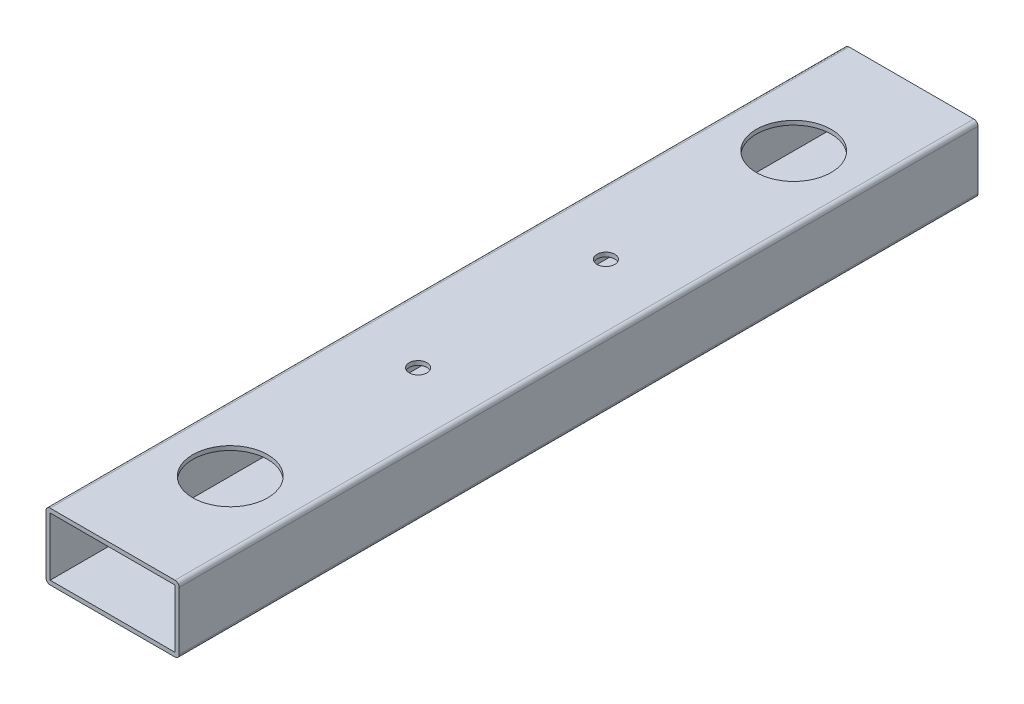
from build123d import *

# Parameters (mm, degrees)
SKETCH1_W                      = 47.625
SKETCH1_H                      = 22.225
BOSS_EXTRUDE1_DEPTH            = 304.8
CUT_EXTRUDE1_REACH             = 27.4
SKETCH2_R                      = 14.2875
CUT_EXTRUDE1_DIRECTION_2_DEPTH = 1
CUT_EXTRUDE2_REACH             = 27.4
SKETCH3_R                      = 12.7
CUT_EXTRUDE2_DIRECTION_2_DEPTH = 1
CUT_EXTRUDE3_REACH             = 27.4
SKETCH4_R                      = 3.3782
CUT_EXTRUDE3_DIRECTION_2_DEPTH = 1
CUT_EXTRUDE4_REACH             = 27.4
SKETCH5_R                      = 7.9375
CUT_EXTRUDE4_DIRECTION_2_DEPTH = 1


with BuildPart() as part:
    # Sketch1 → Boss-Extrude1 (new body)
    with BuildSketch(Plane.XY):
        with BuildLine():
            Line((-23.8125, -12.7), (23.8125, -12.7))
            ThreePointArc((23.8125, -12.7), (24.935032015, -12.235032015), (25.4, -11.1125))
            Line((25.4, -11.1125), (25.4, 11.1125))
            ThreePointArc((25.4, 11.1125), (24.935032015, 12.235032015), (23.8125, 12.7))
            Line((23.8125, 12.7), (-23.8125, 12.7))
            ThreePointArc((-23.8125, 12.7), (-24.935032015, 12.235032015), (-25.4, 11.1125))
            Line((-25.4, 11.1125), (-25.4, -11.1125))
            ThreePointArc((-25.4, -11.1125), (-24.935032015, -12.235032015), (-23.8125, -12.7))
        make_face()
        Rectangle(SKETCH1_W, SKETCH1_H, mode=Mode.SUBTRACT)
    extrude(amount=BOSS_EXTRUDE1_DEPTH)

    # Sketch2 → Cut-Extrude1 (cut, up to next)
    with BuildSketch(Plane(origin=(0, 12.7, 0), x_dir=(1, 0, 0), z_dir=(0, 1, 0)), mode=Mode.PRIVATE) as cut_extrude1_sk1:
        with Locations((0, -259.900000011)):
            Circle(SKETCH2_R)
    cut_extrude1_tool1 = extrude(cut_extrude1_sk1.sketch, amount=-CUT_EXTRUDE1_REACH, mode=Mode.PRIVATE) & part.part
    add(cut_extrude1_tool1.solids().sort_by_distance((0, 12.7, 259.9))[0], mode=Mode.SUBTRACT)
    # Sketch2 → Cut-Extrude1 (cut, up to next)
    with BuildSketch(Plane(origin=(0, 12.7, 0), x_dir=(1, 0, 0), z_dir=(0, 1, 0)), mode=Mode.PRIVATE) as cut_extrude1_sk2:
        with Locations((0, -44.899999989)):
            Circle(SKETCH2_R)
    cut_extrude1_tool2 = extrude(cut_extrude1_sk2.sketch, amount=-CUT_EXTRUDE1_REACH, mode=Mode.PRIVATE) & part.part
    add(cut_extrude1_tool2.solids().sort_by_distance((0, 12.7, 44.9))[0], mode=Mode.SUBTRACT)

    # Sketch2 → Cut-Extrude1 direction 2 (cut)
    with BuildSketch(Plane(origin=(0, 12.7, 0), x_dir=(1, 0, 0), z_dir=(0, 1, 0))):
        with Locations((0, -259.900000011)):
            Circle(SKETCH2_R)
        with Locations((0, -44.899999989)):
            Circle(SKETCH2_R)
    extrude(amount=CUT_EXTRUDE1_DIRECTION_2_DEPTH, mode=Mode.SUBTRACT)

    # Sketch3 → Cut-Extrude2 (cut, up to next)
    with BuildSketch(Plane.XZ.offset(12.7), mode=Mode.PRIVATE) as cut_extrude2_sk1:
        with Locations((0, 44.899999989)):
            Circle(SKETCH3_R)
    cut_extrude2_tool1 = extrude(cut_extrude2_sk1.sketch, amount=-CUT_EXTRUDE2_REACH, mode=Mode.PRIVATE) & part.part
    add(cut_extrude2_tool1.solids().sort_by_distance((0, -12.7, 44.9))[0], mode=Mode.SUBTRACT)
    # Sketch3 → Cut-Extrude2 (cut, up to next)
    with BuildSketch(Plane.XZ.offset(12.7), mode=Mode.PRIVATE) as cut_extrude2_sk2:
        with Locations((0, 259.900000011)):
            Circle(SKETCH3_R)
    cut_extrude2_tool2 = extrude(cut_extrude2_sk2.sketch, amount=-CUT_EXTRUDE2_REACH, mode=Mode.PRIVATE) & part.part
    add(cut_extrude2_tool2.solids().sort_by_distance((0, -12.7, 259.9))[0], mode=Mode.SUBTRACT)

    # Sketch3 → Cut-Extrude2 direction 2 (cut)
    with BuildSketch(Plane.XZ.offset(12.7)):
        with Locations((0, 44.899999989)):
            Circle(SKETCH3_R)
        with Locations((0, 259.900000011)):
            Circle(SKETCH3_R)
    extrude(amount=CUT_EXTRUDE2_DIRECTION_2_DEPTH, mode=Mode.SUBTRACT)

    # Sketch4 → Cut-Extrude3 (cut, up to next)
    with BuildSketch(Plane(origin=(0, 12.7, 0), x_dir=(1, 0, 0), z_dir=(0, 1, 0)), mode=Mode.PRIVATE) as cut_extrude3_sk1:
        with Locations((0, -188.233332829)):
            Circle(SKETCH4_R)
    cut_extrude3_tool1 = extrude(cut_extrude3_sk1.sketch, amount=-CUT_EXTRUDE3_REACH, mode=Mode.PRIVATE) & part.part
    add(cut_extrude3_tool1.solids().sort_by_distance((0, 12.7, 188.233333))[0], mode=Mode.SUBTRACT)
    # Sketch4 → Cut-Extrude3 (cut, up to next)
    with BuildSketch(Plane(origin=(0, 12.7, 0), x_dir=(1, 0, 0), z_dir=(0, 1, 0)), mode=Mode.PRIVATE) as cut_extrude3_sk2:
        with Locations((0, -116.566667171)):
            Circle(SKETCH4_R)
    cut_extrude3_tool2 = extrude(cut_extrude3_sk2.sketch, amount=-CUT_EXTRUDE3_REACH, mode=Mode.PRIVATE) & part.part
    add(cut_extrude3_tool2.solids().sort_by_distance((0, 12.7, 116.566667))[0], mode=Mode.SUBTRACT)

    # Sketch4 → Cut-Extrude3 direction 2 (cut)
    with BuildSketch(Plane(origin=(0, 12.7, 0), x_dir=(1, 0, 0), z_dir=(0, 1, 0))):
        with Locations((0, -188.233332829)):
            Circle(SKETCH4_R)
        with Locations((0, -116.566667171)):
            Circle(SKETCH4_R)
    extrude(amount=CUT_EXTRUDE3_DIRECTION_2_DEPTH, mode=Mode.SUBTRACT)

    # Sketch5 → Cut-Extrude4 (cut, up to next)
    with BuildSketch(Plane.XZ.offset(12.7), mode=Mode.PRIVATE) as cut_extrude4_sk1:
        with Locations((0, 116.566667171)):
            Circle(SKETCH5_R)
    cut_extrude4_tool1 = extrude(cut_extrude4_sk1.sketch, amount=-CUT_EXTRUDE4_REACH, mode=Mode.PRIVATE) & part.part
    add(cut_extrude4_tool1.solids().sort_by_distance((0, -12.7, 116.566667))[0], mode=Mode.SUBTRACT)
    # Sketch5 → Cut-Extrude4 (cut, up to next)
    with BuildSketch(Plane.XZ.offset(12.7), mode=Mode.PRIVATE) as cut_extrude4_sk2:
        with Locations((0, 188.233332829)):
            Circle(SKETCH5_R)
    cut_extrude4_tool2 = extrude(cut_extrude4_sk2.sketch, amount=-CUT_EXTRUDE4_REACH, mode=Mode.PRIVATE) & part.part
    add(cut_extrude4_tool2.solids().sort_by_distance((0, -12.7, 188.233333))[0], mode=Mode.SUBTRACT)

    # Sketch5 → Cut-Extrude4 direction 2 (cut)
    with BuildSketch(Plane.XZ.offset(12.7)):
        with Locations((0, 116.566667171)):
            Circle(SKETCH5_R)
        with Locations((0, 188.233332829)):
            Circle(SKETCH5_R)
    extrude(amount=CUT_EXTRUDE4_DIRECTION_2_DEPTH, mode=Mode.SUBTRACT)


solid = part.part
